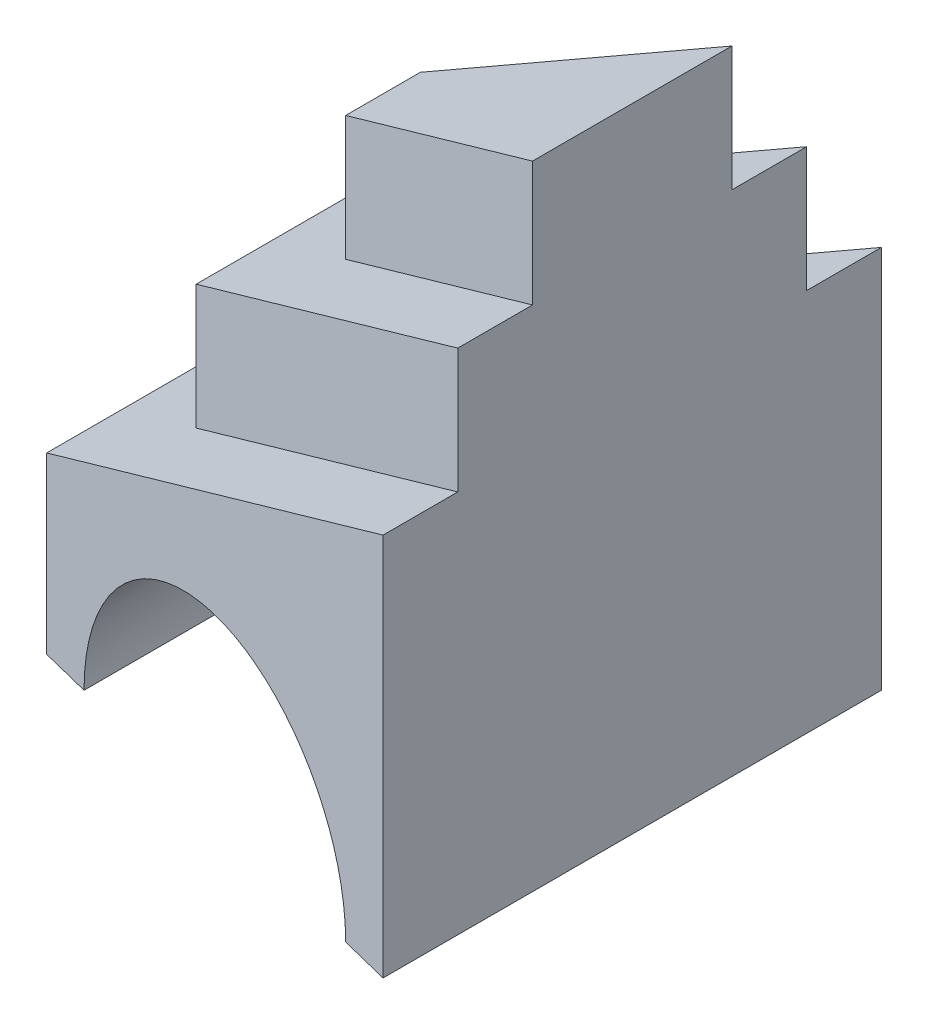
from build123d import *

# Parameters (mm, degrees)
EXTRUDE1_DEPTH = 76.968
EXTRUDE2_DEPTH = 90
EXTRUDE3_DEPTH = 101.968
EXTRUDE4_DEPTH = 76.321
EXTRUDE5_DEPTH = 126.968
EXTRUDE6_DEPTH = 126.968
EXTRUDE7_DEPTH = 88.484


with BuildPart() as part:
    # Sketch1 → Extrude1 (new body)
    with BuildSketch(Plane(origin=(0, 0, 0), x_dir=(1, 0, 0), z_dir=(0, 1, 0))):
        Polygon((0, 0), (0, 55), (90, 77.5), (90, -22.5), align=None)
    extrude(amount=EXTRUDE1_DEPTH)

    # Sketch2 → Extrude2 (cut, symmetric)
    with BuildSketch(Plane.XY):
        Polygon((90, 76.968), (0, 35.000310766), (0, 76.968), align=None)
    extrude(amount=EXTRUDE2_DEPTH, both=True, mode=Mode.SUBTRACT)

    # Sketch3 → Extrude3 (add)
    with BuildSketch(Plane(origin=(0, 0, 0), x_dir=(1, 0, 0), z_dir=(0, 1, 0))):
        Polygon((90, 62.5), (20, 45), (20, 10), (90, -7.5), align=None)
    extrude(amount=EXTRUDE3_DEPTH)

    # Sketch4 → Extrude4 (cut, symmetric)
    with BuildSketch(Plane.XY):
        Polygon((90, 101.968), (20, 69.326463929), (20, 101.968), align=None)
    extrude(amount=EXTRUDE4_DEPTH, both=True, mode=Mode.SUBTRACT)

    # Sketch5 → Extrude5 (add)
    with BuildSketch(Plane(origin=(0, 0, 0), x_dir=(1, 0, 0), z_dir=(0, 1, 0))):
        Polygon((90, 47.5), (40, 35), (40, 20), (90, 7.5), align=None)
    extrude(amount=EXTRUDE5_DEPTH)

    # Sketch6 → Extrude6 (cut)
    with BuildSketch(Plane.XY):
        Polygon((90, 126.968), (40, 103.652617092), (40, 126.968), align=None)
    extrude(amount=-EXTRUDE6_DEPTH, mode=Mode.SUBTRACT)

    # Sketch7 → Extrude7 (cut, symmetric)
    with BuildSketch(Plane.XY):
        with BuildLine():
            Line((80, 0), (10, 0))
            ThreePointArc((10, 0), (45, 35), (80, 0))
        make_face()
    extrude(amount=EXTRUDE7_DEPTH, both=True, mode=Mode.SUBTRACT)


solid = part.part
